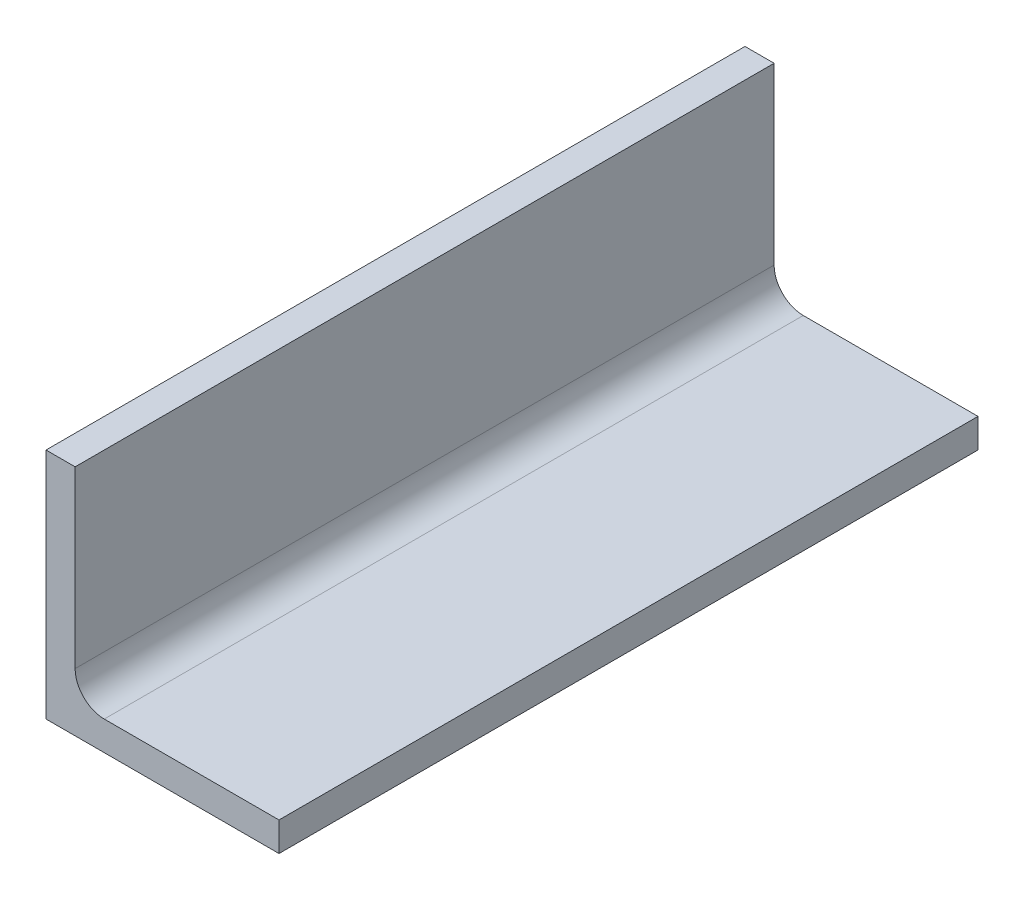
from build123d import *

# Parameters (mm, degrees)
BOSS_EXTRUDE1_DEPTH = 76.2


with BuildPart() as part:
    # Sketch2 → Boss-Extrude1 (new body, symmetric)
    with BuildSketch(Plane.XY):
        with BuildLine():
            Line((0, 0), (0, 50.8))
            Line((0, 50.8), (6.35, 50.8))
            Line((6.35, 50.8), (6.35, 12.7))
            ThreePointArc((6.35, 12.7), (8.209871939, 8.209871939), (12.7, 6.35))
            Line((12.7, 6.35), (50.8, 6.35))
            Line((50.8, 6.35), (50.8, 0))
            Line((50.8, 0), (0, 0))
        make_face()
    extrude(amount=BOSS_EXTRUDE1_DEPTH, both=True)


solid = part.part
